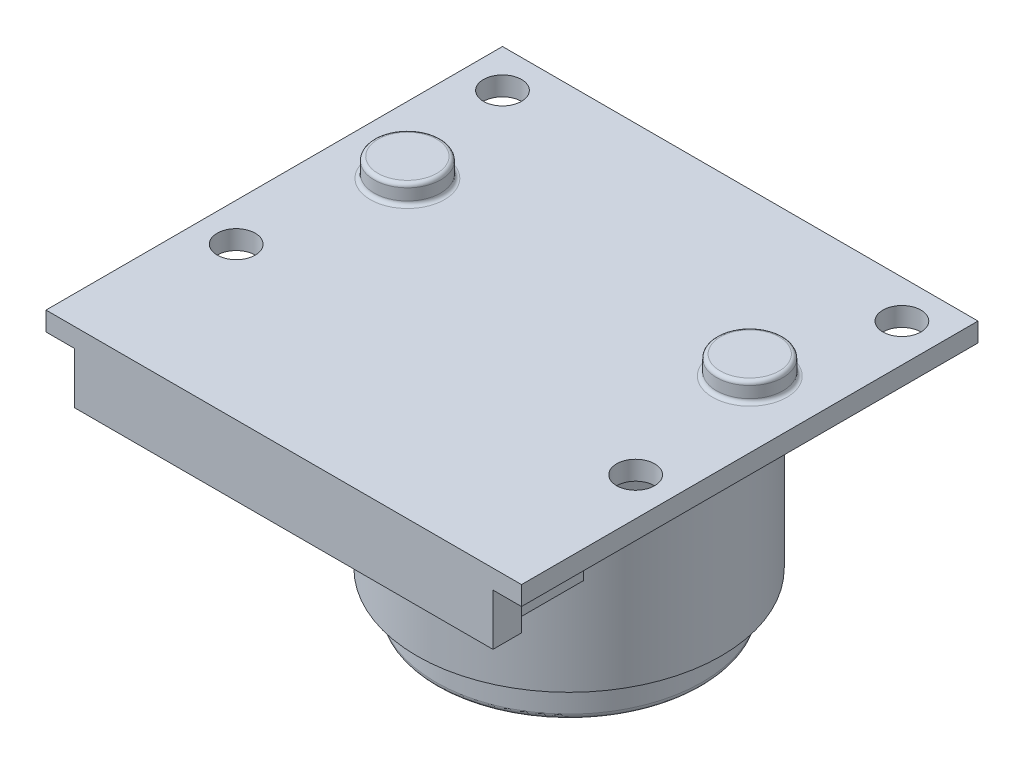
from build123d import *

# Parameters (mm, degrees)
SKETCH_1_W      = 25
SKETCH_1_H      = 24
SKETCH_1_R      = 1
EXTRUDE_1_DEPTH = 1
SKETCH_2_R      = 1.75
EXTRUDE_2_DEPTH = 1
FILLET_1_R      = 0.2
SKETCH_3_W      = 20.5
SKETCH_3_H      = 4
EXTRUDE_3_DEPTH = 2.7
SKETCH_4_R      = 8
EXTRUDE_4_DEPTH = 12
SKETCH_5_R      = 7
EXTRUDE_5_DEPTH = 2
FILLET_2_R      = 0.3


with BuildPart() as part:
    # Эскиз1 → Бобышка-Вытянуть1 (new body)
    with BuildSketch(Plane(origin=(0, 0, 0), x_dir=(1, 0, 0), z_dir=(0, 1, 0))):
        Rectangle(SKETCH_1_W, SKETCH_1_H)
        with Locations((-10.5, 10)):
            Circle(SKETCH_1_R, mode=Mode.SUBTRACT)
        with Locations((10.5, 10)):
            Circle(SKETCH_1_R, mode=Mode.SUBTRACT)
        with Locations((10.5, -4)):
            Circle(SKETCH_1_R, mode=Mode.SUBTRACT)
        with Locations((-10.5, -4)):
            Circle(SKETCH_1_R, mode=Mode.SUBTRACT)
    extrude(amount=EXTRUDE_1_DEPTH)

    # Эскиз2 → Бобышка-Вытянуть2 (add)
    with BuildSketch(Plane(origin=(0, 1, 0), x_dir=(1, 0, 0), z_dir=(0, 1, 0))):
        with Locations((-9, 3.5)):
            Circle(SKETCH_2_R)
        with Locations((9, 3.5)):
            Circle(SKETCH_2_R)
    extrude(amount=EXTRUDE_2_DEPTH)

    # Скругление1
    fillet_1_edges = [part.edges().sort_by_distance(p)[0] for p in [
        (-10.75, 1, -3.5),
        (-10.75, 2, -3.5),
        (7.25, 1, -3.5),
        (7.25, 2, -3.5),
    ]]
    fillet(fillet_1_edges, radius=FILLET_1_R)

    # Эскиз3 → Бобышка-Вытянуть3 (add)
    with BuildSketch(Plane.XZ):
        with Locations((0, 8.5)):
            Rectangle(SKETCH_3_W, SKETCH_3_H)
        Polygon((-11, 10.5), (-10.25, 10.5), (10.25, 10.5), (11, 10.5), (11, 12), (-11, 12), align=None)
    extrude(amount=EXTRUDE_3_DEPTH)

    # Эскиз4 → Бобышка-Вытянуть4 (add)
    with BuildSketch(Plane.XZ):
        with Locations((0, -3)):
            Circle(SKETCH_4_R)
    extrude(amount=EXTRUDE_4_DEPTH)

    # Эскиз5 → Бобышка-Вытянуть5 (add)
    with BuildSketch(Plane.XZ.offset(12)):
        with Locations((0, -3)):
            Circle(SKETCH_5_R)
    extrude(amount=EXTRUDE_5_DEPTH)

    # Скругление2
    fillet_2_edges = [part.edges().sort_by_distance(p)[0] for p in [
        (-7, -14, -3),
    ]]
    fillet(fillet_2_edges, radius=FILLET_2_R)


solid = part.part
